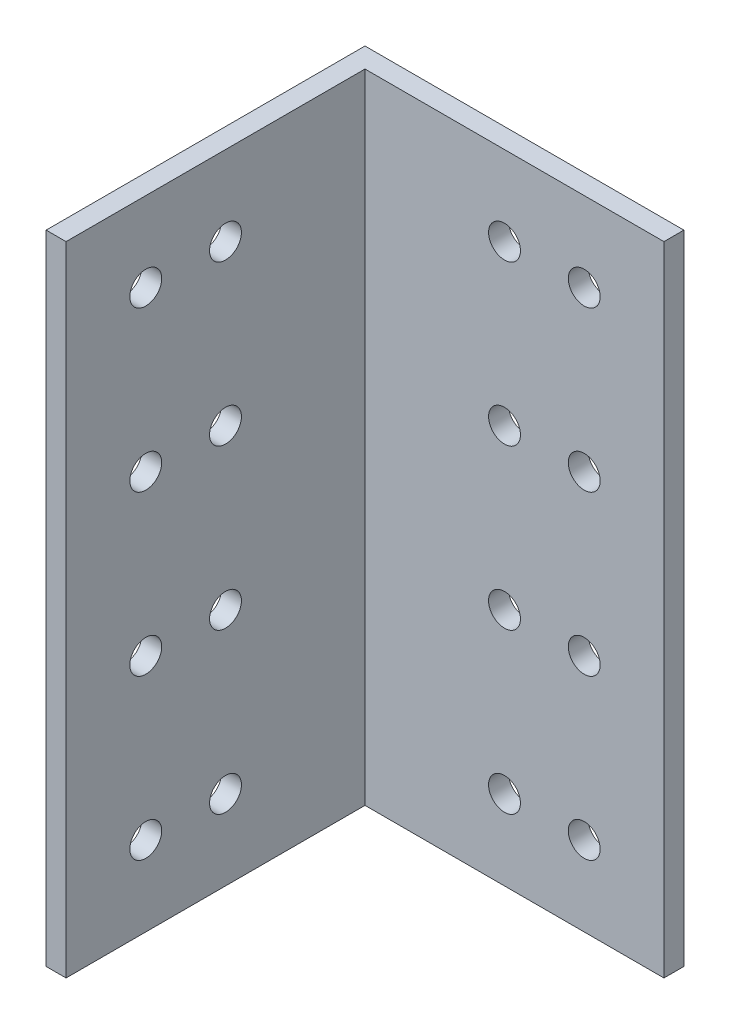
from build123d import *

# Parameters (mm, degrees)
BOSS_EXTRUDE1_DEPTH = 101.6
SKETCH3_R           = 2.54
CUT_EXTRUDE1_DEPTH  = 4.175
SKETCH4_R           = 2.54
CUT_EXTRUDE2_DEPTH  = 4.175


with BuildPart() as part:
    # Sketch2 → Boss-Extrude1 (new body)
    with BuildSketch(Plane(origin=(0, 0, 0), x_dir=(1, 0, 0), z_dir=(0, 1, 0))):
        Polygon((-25.4, 25.4), (-25.4, -25.4), (-22.225, -25.4), (-22.225, 22.225), (25.4, 22.225), (25.4, 25.4), align=None)
    extrude(amount=BOSS_EXTRUDE1_DEPTH)

    # Sketch3 → Cut-Extrude1 (cut, through all)
    with BuildSketch(Plane.XY.offset(-22.225)):
        with Locations((12.7, 88.9)):
            Circle(SKETCH3_R)
        with Locations((0, 88.9)):
            Circle(SKETCH3_R)
        with Locations((0, 63.5)):
            Circle(SKETCH3_R)
        with Locations((12.7, 63.5)):
            Circle(SKETCH3_R)
        with Locations((0, 38.1)):
            Circle(SKETCH3_R)
        with Locations((12.7, 38.1)):
            Circle(SKETCH3_R)
        with Locations((0, 12.7)):
            Circle(SKETCH3_R)
        with Locations((12.7, 12.7)):
            Circle(SKETCH3_R)
    extrude(amount=-CUT_EXTRUDE1_DEPTH, mode=Mode.SUBTRACT)

    # Sketch4 → Cut-Extrude2 (cut, through all)
    with BuildSketch(Plane(origin=(-22.225, 0, 0), x_dir=(0, 0, -1), z_dir=(1, 0, 0))):
        with Locations((-12.7, 88.9)):
            Circle(SKETCH4_R)
        with Locations((0, 88.9)):
            Circle(SKETCH4_R)
        with Locations((-12.7, 63.5)):
            Circle(SKETCH4_R)
        with Locations((0, 63.5)):
            Circle(SKETCH4_R)
        with Locations((-12.7, 38.1)):
            Circle(SKETCH4_R)
        with Locations((0, 38.1)):
            Circle(SKETCH4_R)
        with Locations((-12.7, 12.7)):
            Circle(SKETCH4_R)
        with Locations((0, 12.7)):
            Circle(SKETCH4_R)
    extrude(amount=-CUT_EXTRUDE2_DEPTH, mode=Mode.SUBTRACT)


solid = part.part
